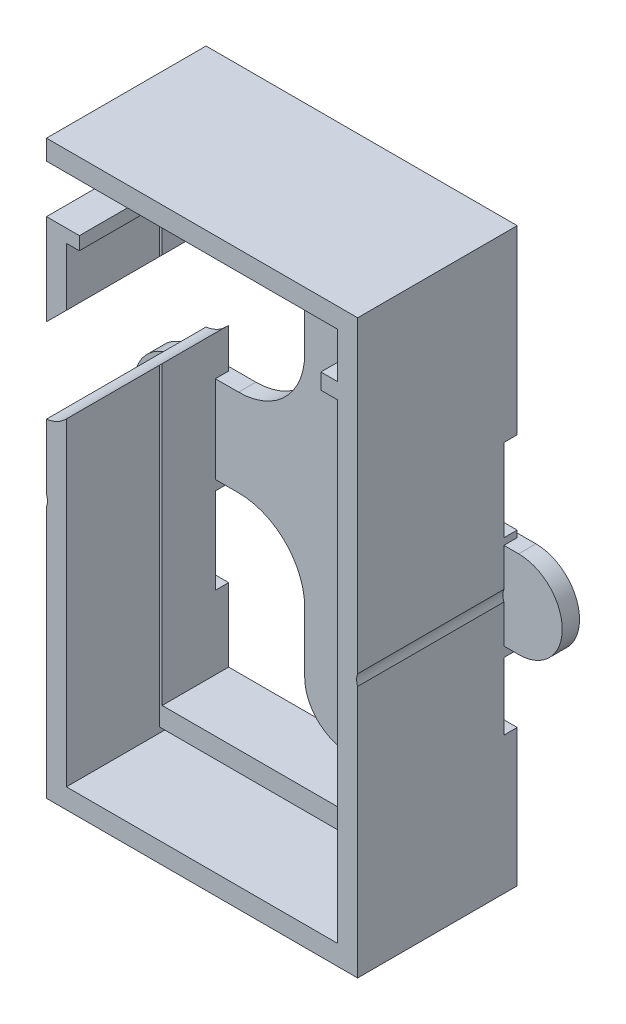
from build123d import *

# Parameters (mm, degrees)
X_WING_DEPTH        = 12.7
SKETCH4_3_R         = 1.5
SKETCH4_3_R_2       = 3.175
HOLES_DEPTH         = 9.525
CHIP_DEPTH          = 6.35
EXTRUDE_9V_DEPTH    = 15.24
SKETCH6_3_R         = 1.27
AIR_HOLES_DEPTH     = 9.525
LIFT_START          = 5.08
LIFT_DEPTH          = 1.27
SKETCH7_W           = 7.542953633
SKETCH7_H           = 7.880697826
SKETCH7_H_2         = 6.417139658
SKETCH7_W_2         = 5.741651273
SKETCH7_H_3         = 8.218442018
AIR_SLOTS_DEPTH     = 1.27
BOSS_EXTRUDE1_DEPTH = 0.381


with BuildPart() as part:
    # Sketch2 → Body (revolve)
    with BuildSketch(Plane(origin=(0, 0, 0), x_dir=(0, 0, -1), z_dir=(1, 0, 0))):
        Polygon((4.4704, 13.9065), (0, 12.5857), (0, 0), (-5.08, 0), (-5.08, 49.53), (64.831152593, 49.53), (64.831152593, 39.37), (59.751152593, 39.37), (59.751152593, 44.45), (0, 44.45), (0, 16.4465), (4.4704, 16.4465), align=None)
    revolve(axis=Axis((0, 0, 0), (0, 0, 1)))

    # Sketch4 → X-Wing (cut)
    with BuildSketch(Plane.XY):
        with BuildLine():
            Line((-4.1656, -12.04250002), (-4.1656, -10.483480973))
            ThreePointArc((-4.1656, -10.483480973), (-6.016064494, -6.016064494), (-10.483480973, -4.1656))
            Line((-10.483480973, -4.1656), (-16.265, -4.1656))
            ThreePointArc((-16.265, -4.1656), (-20.4306, 0), (-16.265, 4.1656))
            Line((-16.265, 4.1656), (-12.04250002, 4.1656))
            Line((-12.04250002, 4.1656), (-10.483480973, 4.1656))
            ThreePointArc((-10.483480973, 4.1656), (-6.016064494, 6.016064494), (-4.1656, 10.483480973))
            Line((-4.1656, 10.483480973), (-4.1656, 12.04250002))
            Line((-4.1656, 12.04250002), (-4.1656, 16.265))
            ThreePointArc((-4.1656, 16.265), (0, 20.4306), (4.1656, 16.265))
            Line((4.1656, 16.265), (4.1656, 12.04250002))
            Line((4.1656, 12.04250002), (4.1656, 10.483480973))
            ThreePointArc((4.1656, 10.483480973), (6.016064494, 6.016064494), (10.483480973, 4.1656))
            Line((10.483480973, 4.1656), (12.04250002, 4.1656))
            Line((12.04250002, 4.1656), (16.265, 4.1656))
            ThreePointArc((16.265, 4.1656), (20.4306, 0), (16.265, -4.1656))
            Line((16.265, -4.1656), (12.04250002, -4.1656))
            Line((12.04250002, -4.1656), (10.483480973, -4.1656))
            ThreePointArc((10.483480973, -4.1656), (6.016064494, -6.016064494), (4.1656, -10.483480973))
            Line((4.1656, -10.483480973), (4.1656, -12.04250002))
            Line((4.1656, -12.04250002), (4.1656, -16.265))
            ThreePointArc((4.1656, -16.265), (0, -20.4306), (-4.1656, -16.265))
            Line((-4.1656, -16.265), (-4.1656, -12.04250002))
        make_face()
    extrude(amount=-X_WING_DEPTH, mode=Mode.SUBTRACT)

    # Sketch4_3 → Holes (cut)
    with BuildSketch(Plane.XY):
        with Locations(Location((0, -16.265, 0), (0, 0, 180))):
            Circle(SKETCH4_3_R)
        with Locations(Location((-16.265, 0, 0), (0, 0, 180))):
            Circle(SKETCH4_3_R)
        with Locations(Location((16.265, 0, 0), (0, 0, 180))):
            Circle(SKETCH4_3_R)
        with Locations(Location((0, 16.265, 0), (0, 0, 180))):
            Circle(SKETCH4_3_R)
        with BuildLine():
            ThreePointArc((-7.633217703, 13.021371376), (-7.633217703, 17.511499436), (-12.123345763, 17.511499436))
            Line((-12.123345763, 17.511499436), (-17.511499436, 12.123345763))
            ThreePointArc((-17.511499436, 12.123345763), (-17.511499436, 7.633217703), (-13.021371376, 7.633217703))
            Line((-13.021371376, 7.633217703), (-7.633217703, 13.021371376))
        make_face()
        with Locations((-8.261128525, 8.261128525)):
            Circle(SKETCH4_3_R_2)
        with Locations(Location((8.261128525, 8.261128525, 0), (0, 0, 125.826899667))):
            Circle(SKETCH4_3_R_2)
        with Locations(Location((8.261128525, -8.261128525, 0), (0, 0, 234.173100333))):
            Circle(SKETCH4_3_R_2)
        with Locations(Location((-8.261128525, -8.261128525, 0), (0, 0, 144.173100333))):
            Circle(SKETCH4_3_R_2)
    extrude(amount=HOLES_DEPTH, mode=Mode.SUBTRACT)

    # Sketch6 → Chip (add)
    with BuildSketch(Plane.XY.offset(5.08)):
        Polygon((11.350015507, 22.225), (-11.715690517, 22.225), (-12.954, 22.225), (-12.954, 16.6808452), (-12.7, 16.9348452), (-12.7, 20.32), (12.7, 20.32), (12.7, -20.32), (-12.7, -20.32), (-12.7, 7.954589078), (-12.954, 7.700589078), (-12.954, -22.225), (12.954, -22.225), (12.954, 22.225), align=None)
    extrude(amount=CHIP_DEPTH)

    # Sketch6_4 → Extrude 9V (add)
    with BuildSketch(Plane.XY.offset(5.08)):
        Polygon((-14.859, 14.7758452), (-12.954, 16.6808452), (-12.954, 22.225), (-11.715690517, 22.225), (-11.715690517, 23.479848526), (-14.859, 23.479848526), align=None)
        with BuildLine():
            ThreePointArc((-13.021371376, 7.633217703), (-13.865328691, 7.029154679), (-14.859, 6.729532555))
            Line((-14.859, 6.729532555), (-14.859, 0.522650935))
            ThreePointArc((-14.859, 0.522650935), (-14.765, 0), (-14.859, -0.522650935))
            Line((-14.859, -0.522650935), (-14.859, -24.638))
            Line((-14.859, -24.638), (14.859, -24.638))
            Line((14.859, -24.638), (14.859, -0.522650935))
            ThreePointArc((14.859, -0.522650935), (14.765, 0), (14.859, 0.522650935))
            Line((14.859, 0.522650935), (14.859, 29.972))
            Line((14.859, 29.972), (-14.859, 29.972))
            Line((-14.859, 29.972), (-14.859, 28.067))
            Line((-14.859, 28.067), (12.954, 28.067))
            Line((12.954, 28.067), (12.954, 23.734213344))
            Line((12.954, 23.734213344), (11.350015507, 23.734213344))
            Line((11.350015507, 23.734213344), (11.350015507, 22.225))
            Line((11.350015507, 22.225), (12.954, 22.225))
            Line((12.954, 22.225), (12.954, -22.733))
            Line((12.954, -22.733), (-12.954, -22.733))
            Line((-12.954, -22.733), (-12.954, 7.700589078))
            Line((-12.954, 7.700589078), (-13.021371376, 7.633217703))
        make_face()
    extrude(amount=EXTRUDE_9V_DEPTH)

    # Sketch6_3 → Air holes (cut)
    with BuildSketch(Plane.XY.offset(5.08)):
        with Locations((-23.749, -23.368)):
            Circle(SKETCH6_3_R)
        with Locations((23.114, -15.748)):
            Circle(SKETCH6_3_R)
        with Locations((-9.906, 36.322)):
            Circle(SKETCH6_3_R)
        with Locations((18.034, 36.322)):
            Circle(SKETCH6_3_R)
    extrude(amount=-AIR_HOLES_DEPTH, mode=Mode.SUBTRACT)

    # Sketch4_4 → Lift (add)
    with BuildSketch(Plane.XY.offset(LIFT_START)):
        with BuildLine():
            Line((-4.1656, -12.04250002), (-4.1656, -10.483480973))
            ThreePointArc((-4.1656, -10.483480973), (-6.016064494, -6.016064494), (-10.483480973, -4.1656))
            Line((-10.483480973, -4.1656), (-16.265, -4.1656))
            ThreePointArc((-16.265, -4.1656), (-20.4306, 0), (-16.265, 4.1656))
            Line((-16.265, 4.1656), (-12.04250002, 4.1656))
            Line((-12.04250002, 4.1656), (-10.483480973, 4.1656))
            ThreePointArc((-10.483480973, 4.1656), (-6.016064494, 6.016064494), (-4.1656, 10.483480973))
            Line((-4.1656, 10.483480973), (-4.1656, 12.04250002))
            Line((-4.1656, 12.04250002), (-4.1656, 16.265))
            ThreePointArc((-4.1656, 16.265), (0, 20.4306), (4.1656, 16.265))
            Line((4.1656, 16.265), (4.1656, 12.04250002))
            Line((4.1656, 12.04250002), (4.1656, 10.483480973))
            ThreePointArc((4.1656, 10.483480973), (6.016064494, 6.016064494), (10.483480973, 4.1656))
            Line((10.483480973, 4.1656), (12.04250002, 4.1656))
            Line((12.04250002, 4.1656), (16.265, 4.1656))
            ThreePointArc((16.265, 4.1656), (20.4306, 0), (16.265, -4.1656))
            Line((16.265, -4.1656), (12.04250002, -4.1656))
            Line((12.04250002, -4.1656), (10.483480973, -4.1656))
            ThreePointArc((10.483480973, -4.1656), (6.016064494, -6.016064494), (4.1656, -10.483480973))
            Line((4.1656, -10.483480973), (4.1656, -12.04250002))
            Line((4.1656, -12.04250002), (4.1656, -16.265))
            ThreePointArc((4.1656, -16.265), (0, -20.4306), (-4.1656, -16.265))
            Line((-4.1656, -16.265), (-4.1656, -12.04250002))
        make_face()
    extrude(amount=LIFT_DEPTH)

    # Sketch7 → Air Slots (cut)
    with BuildSketch(Plane.XY.offset(5.08)):
        with Locations((15.537525525, 8.731732869)):
            Rectangle(SKETCH7_W, SKETCH7_H)
        with Locations((15.537525525, -8.324348854)):
            Rectangle(SKETCH7_W, SKETCH7_H_2)
        with Locations((-14.859451804, -9.225000034)):
            Rectangle(SKETCH7_W_2, SKETCH7_H_3)
    extrude(amount=AIR_SLOTS_DEPTH, mode=Mode.SUBTRACT)

    # SurfaceCut1
    split(bisect_by=Plane.XY.offset(5.08), keep=Keep.TOP)

    # Sketch9 → Boss-Extrude1 (add)
    with BuildSketch(Plane(origin=(0, 0, 5.08), x_dir=(-1, 0, 0), z_dir=(0, 0, -1))):
        with BuildLine():
            Line((4.1656, 10.483480973), (4.1656, 16.265))
            ThreePointArc((4.1656, 16.265), (3.265287264, 18.8515271), (0.953518935, 20.32))
            Line((0.953518935, 20.32), (-0.953518935, 20.32))
            ThreePointArc((-0.953518935, 20.32), (-3.265287264, 18.8515271), (-4.1656, 16.265))
            Line((-4.1656, 16.265), (-4.1656, 10.483480973))
            ThreePointArc((-4.1656, 10.483480973), (-6.016064494, 6.016064494), (-10.483480973, 4.1656))
            Line((-10.483480973, 4.1656), (-12.7, 4.1656))
            Line((-12.7, 4.1656), (-14.859, 4.1656))
            Line((-14.859, 4.1656), (-16.265, 4.1656))
            ThreePointArc((-16.265, 4.1656), (-20.4306, 0), (-16.265, -4.1656))
            Line((-16.265, -4.1656), (-14.859, -4.1656))
            Line((-14.859, -4.1656), (-12.7, -4.1656))
            Line((-12.7, -4.1656), (-10.483480973, -4.1656))
            ThreePointArc((-10.483480973, -4.1656), (-6.016064494, -6.016064494), (-4.1656, -10.483480973))
            Line((-4.1656, -10.483480973), (-4.1656, -16.265))
            ThreePointArc((-4.1656, -16.265), (-3.265287264, -18.8515271), (-0.953518935, -20.32))
            Line((-0.953518935, -20.32), (0.953518935, -20.32))
            ThreePointArc((0.953518935, -20.32), (3.265287264, -18.8515271), (4.1656, -16.265))
            Line((4.1656, -16.265), (4.1656, -10.483480973))
            ThreePointArc((4.1656, -10.483480973), (6.016064494, -6.016064494), (10.483480973, -4.1656))
            Line((10.483480973, -4.1656), (12.7, -4.1656))
            Line((12.7, -4.1656), (14.859, -4.1656))
            Line((14.859, -4.1656), (16.265, -4.1656))
            ThreePointArc((16.265, -4.1656), (20.4306, 0), (16.265, 4.1656))
            Line((16.265, 4.1656), (14.859, 4.1656))
            Line((14.859, 4.1656), (12.7, 4.1656))
            Line((12.7, 4.1656), (10.483480973, 4.1656))
            ThreePointArc((10.483480973, 4.1656), (6.016064494, 6.016064494), (4.1656, 10.483480973))
        make_face()
    extrude(amount=BOSS_EXTRUDE1_DEPTH)


solid = part.part
